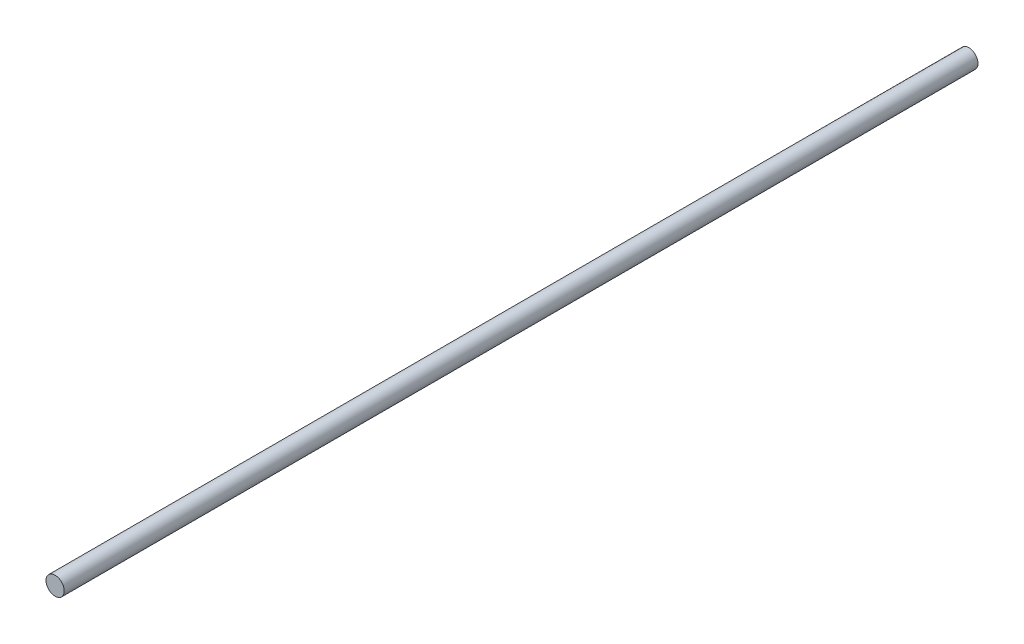
from build123d import *

# Parameters (mm, degrees)
SKETCH_1_R      = 5
EXTRUDE_1_DEPTH = 500


with BuildPart() as part:
    # 草图1 → 凸台-拉伸1 (new body)
    with BuildSketch(Plane.XY):
        Circle(SKETCH_1_R)
    extrude(amount=EXTRUDE_1_DEPTH)


solid = part.part
